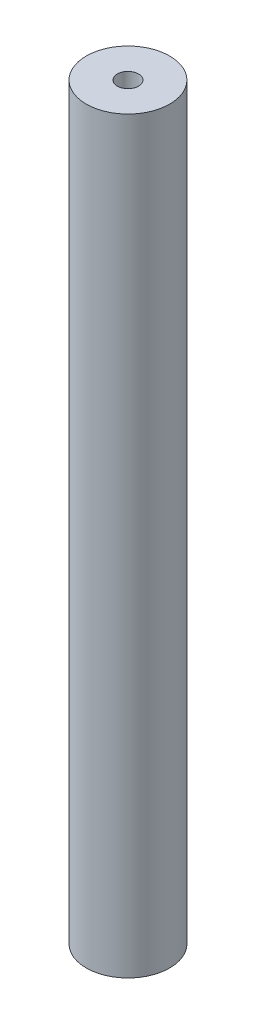
from build123d import *

# Parameters (mm, degrees)
SKETCH1_R           = 4.445
SKETCH1_R_2         = 1.1303
BOSS_EXTRUDE1_DEPTH = 79.756


with BuildPart() as part:
    # Sketch1 → Boss-Extrude1 (new body)
    with BuildSketch(Plane(origin=(0, 0, 0), x_dir=(1, 0, 0), z_dir=(0, 1, 0))):
        Circle(SKETCH1_R)
        Circle(SKETCH1_R_2, mode=Mode.SUBTRACT)
    extrude(amount=BOSS_EXTRUDE1_DEPTH)


solid = part.part
